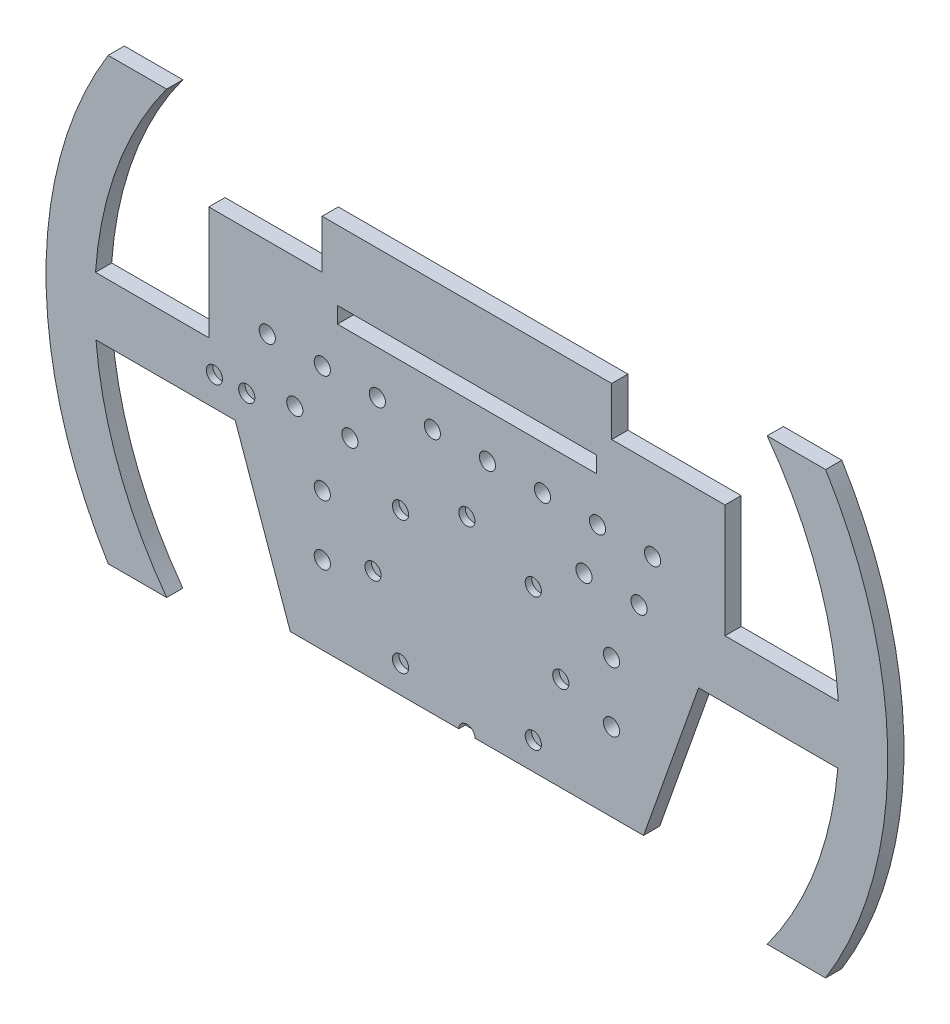
from build123d import *

# Parameters (mm, degrees)
BOSS_EXTRU_1_DEPTH       = 5
ESQUISSE2_W              = 80
ESQUISSE2_H              = 5
ENL_V_MAT_EXTRU_1_DEPTH  = 10
ESQUISSE3_R              = 2.5
ENL_V_MAT_EXTRU_6_DEPTH  = 2
ESQUISSE5_R              = 2.5
ENL_V_MAT_EXTRU_10_DEPTH = 2
ESQUISSE6_R              = 2.5
ENL_V_MAT_EXTRU_12_DEPTH = 6


with BuildPart() as part:
    # Esquisse1 → Boss.-Extru.1 (new body)
    with BuildSketch(Plane.XY):
        with BuildLine():
            Line((-79.721401665, 25), (-79.721401665, -10))
            Line((-79.721401665, -10), (-114.721401665, -10))
            ThreePointArc((-114.721401665, -10), (-114.995625295, -19.003076756), (-114.564392374, -28))
            Line((-114.564392374, -28), (-71.564392374, -28))
            Line((-71.564392374, -28), (-54.56, -76))
            Line((-54.56, -76), (54.56, -76))
            Line((54.56, -76), (71.564392374, -28))
            Line((71.564392374, -28), (114.564392374, -28))
            ThreePointArc((114.564392374, -28), (114.995625295, -19.003076756), (114.721401665, -10))
            Line((114.721401665, -10), (79.721401665, -10))
            Line((79.721401665, -10), (79.721401665, 25))
            Line((79.721401665, 25), (44.721401665, 25))
            Line((44.721401665, 25), (44.721401665, 40))
            Line((44.721401665, 40), (-44.721401665, 40))
            Line((-44.721401665, 40), (-44.721401665, 25))
            Line((-44.721401665, 25), (-79.721401665, 25))
        make_face()
        with BuildLine():
            ThreePointArc((-92.741576437, 50), (-115, -18), (-92.741576437, -86))
            Line((-92.741576437, -86), (-110.797111876, -86))
            ThreePointArc((-110.797111876, -86), (-130, -18), (-110.797111876, 50))
            Line((-110.797111876, 50), (-92.741576437, 50))
        make_face()
        with BuildLine():
            ThreePointArc((92.741576437, 50), (115, -18), (92.741576437, -86))
            Line((92.741576437, -86), (110.797111876, -86))
            ThreePointArc((110.797111876, -86), (130, -18), (110.797111876, 50))
            Line((110.797111876, 50), (92.741576437, 50))
        make_face()
    extrude(amount=BOSS_EXTRU_1_DEPTH)

    # Esquisse2 → Enlèv. mat.-Extru.1 (cut)
    with BuildSketch(Plane.XY.offset(5)):
        with Locations((0, 16)):
            Rectangle(ESQUISSE2_W, ESQUISSE2_H)
    extrude(amount=-ENL_V_MAT_EXTRU_1_DEPTH, mode=Mode.SUBTRACT)

    # Esquisse3 → Enlèv. mat.-Extru.6 (cut)
    with BuildSketch(Plane.XY.offset(5)):
        with Locations((-68, -19)):
            Circle(ESQUISSE3_R)
        with Locations((-78, -19)):
            Circle(ESQUISSE3_R)
    extrude(amount=-ENL_V_MAT_EXTRU_6_DEPTH, mode=Mode.SUBTRACT)

    # Esquisse5 → Enlèv. mat.-Extru.10 (cut)
    with BuildSketch(Plane.XY.offset(5)):
        with Locations((-29, -47)):
            Circle(ESQUISSE5_R)
        with Locations((-20.506096654, -67.506096654)):
            Circle(ESQUISSE5_R)
        with BuildLine():
            Line((-2.5, -76), (2.5, -76))
            ThreePointArc((2.5, -76), (0, -73.5), (-2.5, -76))
        make_face()
        with Locations((20.506096654, -67.506096654)):
            Circle(ESQUISSE5_R)
        with Locations((29, -47)):
            Circle(ESQUISSE5_R)
        with Locations((20.506096654, -26.493903346)):
            Circle(ESQUISSE5_R)
        with Locations((0, -18)):
            Circle(ESQUISSE5_R)
        with Locations((-20.506096654, -26.493903346)):
            Circle(ESQUISSE5_R)
    extrude(amount=-ENL_V_MAT_EXTRU_10_DEPTH, mode=Mode.SUBTRACT)

    # Esquisse6 → Enlèv. mat.-Extru.12 (cut, through all)
    with BuildSketch(Plane.XY.offset(5)):
        with Locations((-61.659877018, 0)):
            Circle(ESQUISSE6_R)
        with Locations((-44.659877018, 0)):
            Circle(ESQUISSE6_R)
        with Locations((-27.659877018, 0)):
            Circle(ESQUISSE6_R)
        with Locations((-10.659877018, 0)):
            Circle(ESQUISSE6_R)
        with Locations((6.340122982, 0)):
            Circle(ESQUISSE6_R)
        with Locations((23.340122982, 0)):
            Circle(ESQUISSE6_R)
        with Locations((40.340122982, 0)):
            Circle(ESQUISSE6_R)
        with Locations((57.340122982, 0)):
            Circle(ESQUISSE6_R)
        with Locations((-53.159877018, -15.034569708)):
            Circle(ESQUISSE6_R)
        with Locations((-36.159877018, -15.034569708)):
            Circle(ESQUISSE6_R)
        with Locations((-44.659877018, -33.372561191)):
            Circle(ESQUISSE6_R)
        with Locations((-44.659877018, -51.87866202)):
            Circle(ESQUISSE6_R)
        with Locations((44.659877018, -51.87866202)):
            Circle(ESQUISSE6_R)
        with Locations((44.659877018, -33.372561191)):
            Circle(ESQUISSE6_R)
        with Locations((36.159877018, -15.034569708)):
            Circle(ESQUISSE6_R)
        with Locations((53.159877018, -15.034569708)):
            Circle(ESQUISSE6_R)
    extrude(amount=-ENL_V_MAT_EXTRU_12_DEPTH, mode=Mode.SUBTRACT)


solid = part.part
